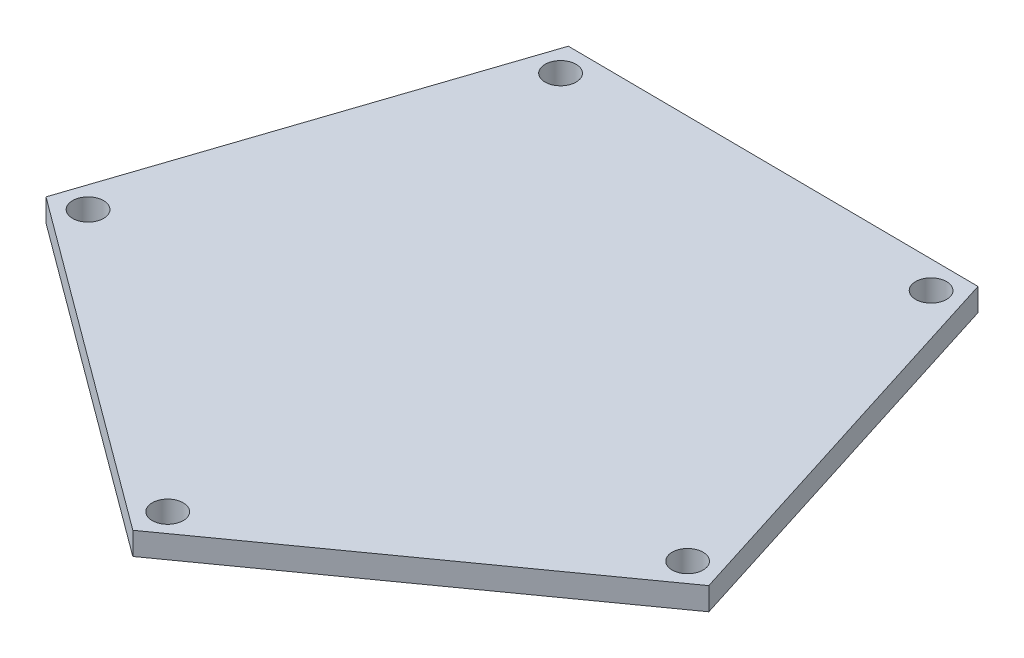
from build123d import *

# Parameters (mm, degrees)
SKETCH1_R           = 7.5
BOSS_EXTRUDE4_DEPTH = 11


with BuildPart() as part:
    # Sketch1 → Boss-Extrude4 (new body)
    with BuildSketch(Plane(origin=(0, 0, 0), x_dir=(1, 0, 0), z_dir=(0, 1, 0))):
        Polygon((161.385398237, -53.842596019), (101.078182497, 136.848357437), (-98.915645933, 138.419532219), (-162.211413702, -51.300381819), (-1.336521099, -170.124911819), align=None)
        with Locations((-89.470042251, 125.201643069)):
            Circle(SKETCH1_R, mode=Mode.SUBTRACT)
        with Locations((-146.717669584, -46.414061546)):
            Circle(SKETCH1_R, mode=Mode.SUBTRACT)
        with Locations((-0.668260549, -153.881551933)):
            Circle(SKETCH1_R, mode=Mode.SUBTRACT)
        with Locations((145.974464027, -48.701085609)):
            Circle(SKETCH1_R, mode=Mode.SUBTRACT)
        with Locations((91.426074949, 123.780502128)):
            Circle(SKETCH1_R, mode=Mode.SUBTRACT)
    extrude(amount=BOSS_EXTRUDE4_DEPTH)


solid = part.part
